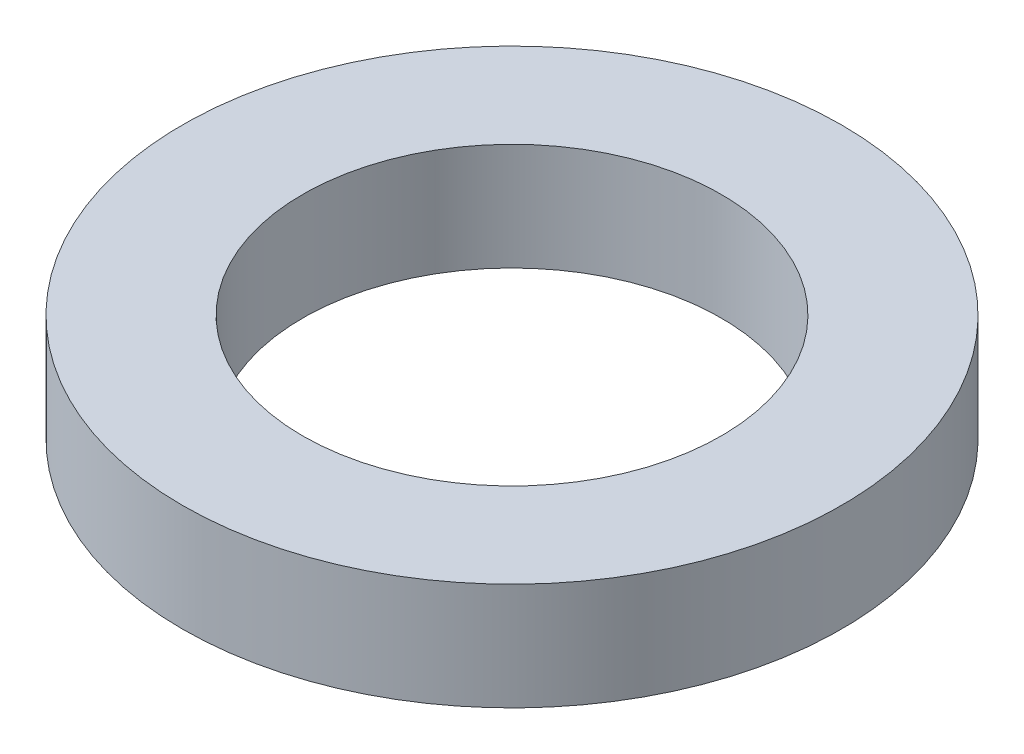
from build123d import *

# Parameters (mm, degrees)
SKETCH1_R           = 2.5
SKETCH1_R_2         = 1.5875
BOSS_EXTRUDE1_DEPTH = 0.8128


with BuildPart() as part:
    # Sketch1 → Boss-Extrude1 (new body)
    with BuildSketch(Plane(origin=(0, 0, 0), x_dir=(1, 0, 0), z_dir=(0, 1, 0))):
        Circle(SKETCH1_R)
        Circle(SKETCH1_R_2, mode=Mode.SUBTRACT)
    extrude(amount=BOSS_EXTRUDE1_DEPTH)


solid = part.part
